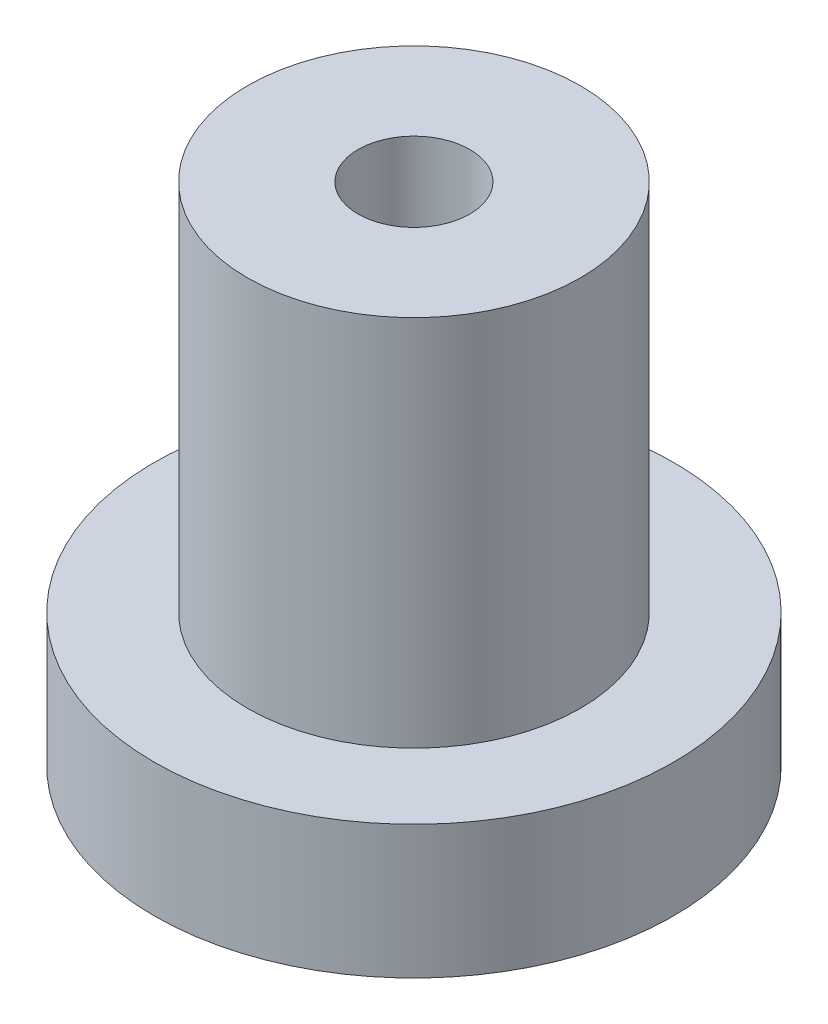
from build123d import *

# Parameters (mm, degrees)
CROQUIS1_R              = 9.75
SALIENTE_EXTRUIR1_DEPTH = 5
CROQUIS2_R              = 6.25
SALIENTE_EXTRUIR2_DEPTH = 14
CROQUIS3_R              = 2.1
CORTAR_EXTRUIR1_DEPTH   = 44


with BuildPart() as part:
    # Croquis1 → Saliente-Extruir1 (new body)
    with BuildSketch(Plane(origin=(0, 0, 0), x_dir=(1, 0, 0), z_dir=(0, 1, 0))):
        Circle(CROQUIS1_R)
    extrude(amount=SALIENTE_EXTRUIR1_DEPTH)

    # Croquis2 → Saliente-Extruir2 (add)
    with BuildSketch(Plane(origin=(0, 5, 0), x_dir=(1, 0, 0), z_dir=(0, 1, 0))):
        Circle(CROQUIS2_R)
    extrude(amount=SALIENTE_EXTRUIR2_DEPTH)

    # Croquis3 → Cortar-Extruir1 (cut)
    with BuildSketch(Plane(origin=(0, 19, 0), x_dir=(1, 0, 0), z_dir=(0, 1, 0))):
        Circle(CROQUIS3_R)
    extrude(amount=-CORTAR_EXTRUIR1_DEPTH, mode=Mode.SUBTRACT)


solid = part.part
